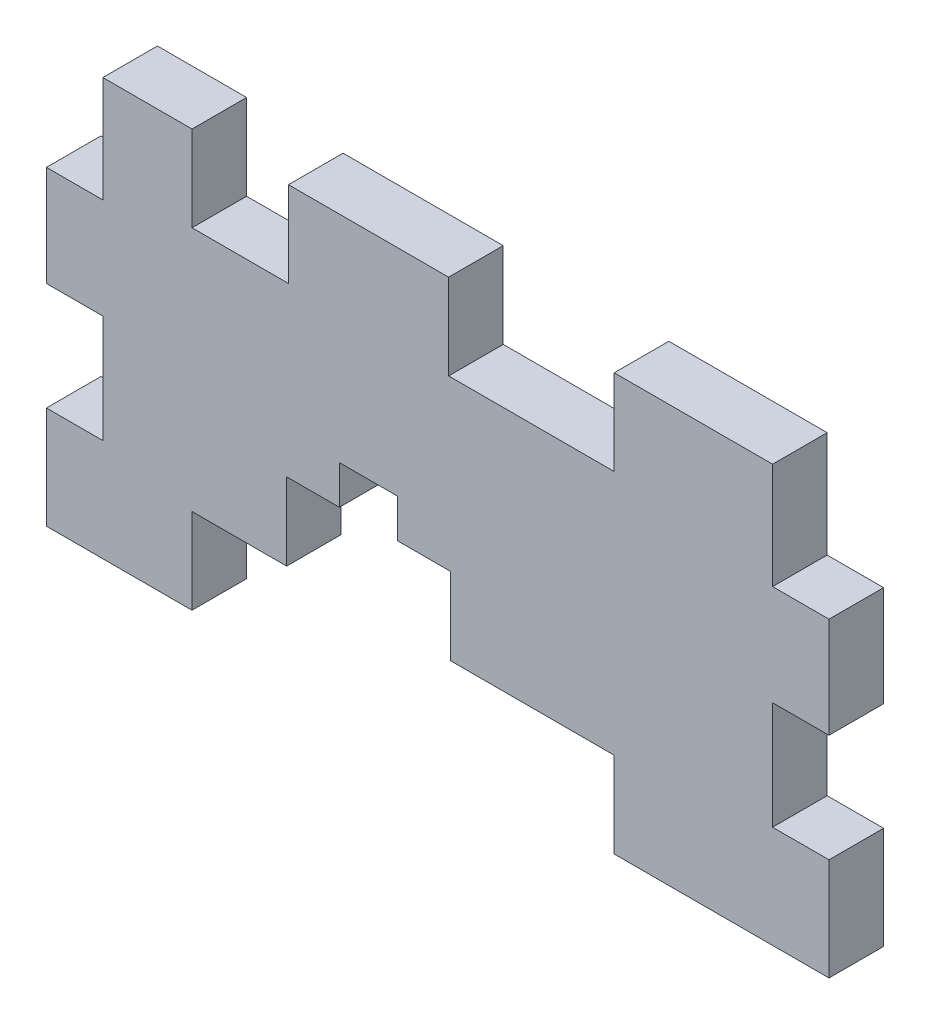
from build123d import *

# Parameters (mm, degrees)
BOSS_EXTRUDE1_DEPTH = 3
SKETCH4_W           = 3.2
SKETCH4_H           = 5.925
SKETCH4_W_2         = 23.2
SKETCH4_H_2         = 4.8
SKETCH4_W_3         = 9.1
SKETCH4_W_4         = 5.3
SKETCH4_H_3         = 2.225
CUT_EXTRUDE2_DEPTH  = 4


with BuildPart() as part:
    # Sketch1 → Boss-Extrude1 (new body)
    with BuildSketch(Plane.XY):
        Polygon((21.5, 37.95), (-21.5, 37.95), (-21.5, 15.05), (-8.3, 15.05), (-8.3, 24), (0.7, 24), (0.7, 15.05), (21.5, 15.05), align=None)
    extrude(amount=BOSS_EXTRUDE1_DEPTH)

    # Sketch4 → Cut-Extrude2 (cut, through all)
    with BuildSketch(Plane.XY):
        with Locations((20, 23.6375)):
            Rectangle(SKETCH4_W, SKETCH4_H)
        with Locations((20, 35.0875)):
            Rectangle(SKETCH4_W, SKETCH4_H)
        with Locations((-1.9, 17.35)):
            Rectangle(SKETCH4_W_2, SKETCH4_H_2)
        with Locations((5.15, 35.65)):
            Rectangle(SKETCH4_W_3, SKETCH4_H_2)
        with Locations((-20, 23.6375)):
            Rectangle(SKETCH4_W, SKETCH4_H)
        with Locations((-20, 35.0875)):
            Rectangle(SKETCH4_W, SKETCH4_H)
        with Locations((-10.85, 35.65)):
            Rectangle(SKETCH4_W_4, SKETCH4_H_2)
        with Locations((-3.8, 25.0125)):
            Rectangle(SKETCH4_W, SKETCH4_H_3)
    extrude(amount=CUT_EXTRUDE2_DEPTH, mode=Mode.SUBTRACT)


solid = part.part
